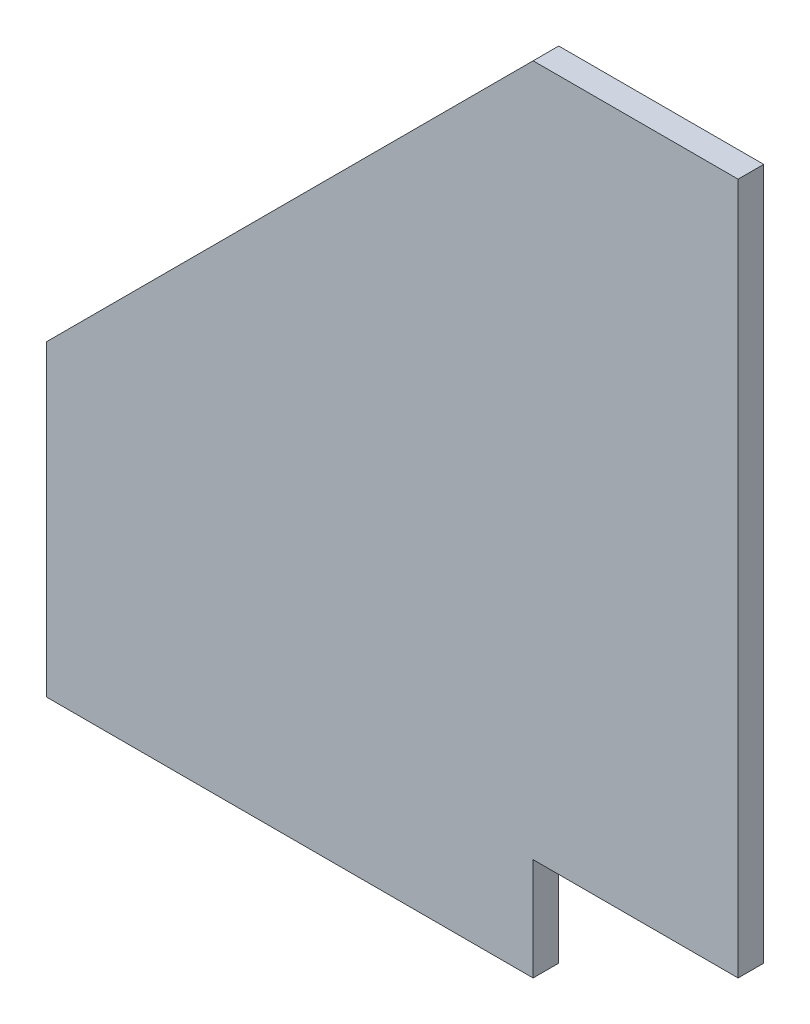
from build123d import *

# Parameters (mm, degrees)
BOSS_EXTRUDE1_DEPTH = 3.175


with BuildPart() as part:
    # Sketch1 → Boss-Extrude1 (new body, symmetric)
    with BuildSketch(Plane.XY):
        Polygon((0, 0), (120.65, 0), (120.65, 25.4), (171.45, 25.4), (171.45, 196.85), (120.65, 196.85), (0, 76.2), align=None)
    extrude(amount=BOSS_EXTRUDE1_DEPTH, both=True)


solid = part.part
